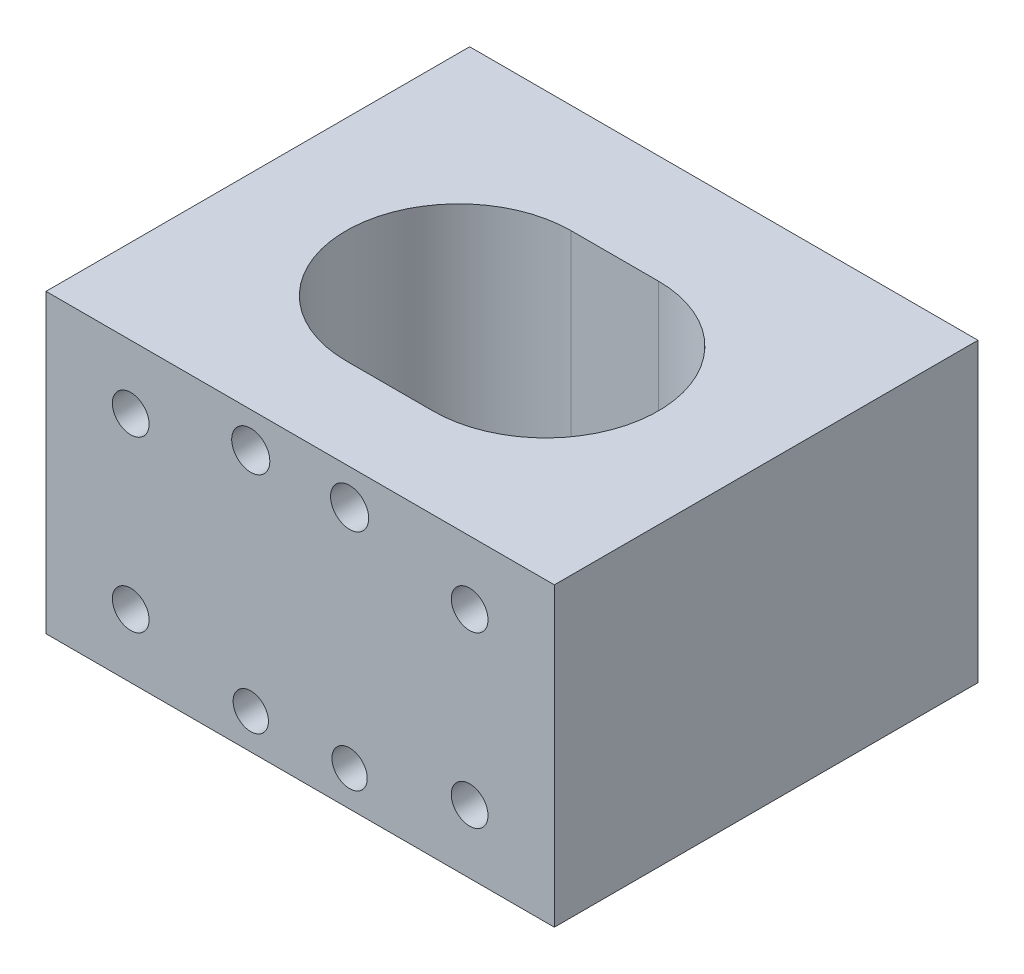
from build123d import *

# Parameters (mm, degrees)
SKETCH_1_W          = 36
SKETCH_1_H          = 21
SKETCH_1_R          = 1.25
SKETCH_1_R_2        = 1.3
SKETCH_1_R_3        = 1.35
EXTRUDE_1_DEPTH     = 30
SKETCH_1_5_R        = 1.3
SKETCH_1_5_R_2      = 1.35
SKETCH_1_5_R_3      = 1.25
CUT_EXTRUDE_1_DEPTH = 4
CUT_EXTRUDE_START   = 30
SKETCH_1_6_R        = 1.35
SKETCH_1_6_R_2      = 1.3
SKETCH_1_6_R_3      = 1.25
CUT_EXTRUDE_2_DEPTH = 4
CUT_EXTRUDE1_DEPTH  = 30


with BuildPart() as part:
    # 스케치1 → 보스-돌출1 (new body)
    with BuildSketch(Plane.XY):
        Rectangle(SKETCH_1_W, SKETCH_1_H)
        with Locations((-3.5, -8)):
            Circle(SKETCH_1_R, mode=Mode.SUBTRACT)
        with Locations((3.5, -8)):
            Circle(SKETCH_1_R, mode=Mode.SUBTRACT)
        with Locations((-12, 6)):
            Circle(SKETCH_1_R_2, mode=Mode.SUBTRACT)
        with Locations((12, 6)):
            Circle(SKETCH_1_R_2, mode=Mode.SUBTRACT)
        with Locations((12, -6)):
            Circle(SKETCH_1_R_2, mode=Mode.SUBTRACT)
        with Locations((-12, -6)):
            Circle(SKETCH_1_R_2, mode=Mode.SUBTRACT)
        with Locations((3.5, 8)):
            Circle(SKETCH_1_R_3, mode=Mode.SUBTRACT)
        with Locations((-3.5, 8)):
            Circle(SKETCH_1_R_3, mode=Mode.SUBTRACT)
        with Locations((12, -6)):
            Circle(SKETCH_1_R_2)
        with Locations((3.5, -8)):
            Circle(SKETCH_1_R)
        with Locations((-3.5, -8)):
            Circle(SKETCH_1_R)
        with Locations((-12, -6)):
            Circle(SKETCH_1_R_2)
        with Locations((-12, 6)):
            Circle(SKETCH_1_R_2)
        with Locations((-3.5, 8)):
            Circle(SKETCH_1_R_3)
        with Locations((3.5, 8)):
            Circle(SKETCH_1_R_3)
        with Locations((12, 6)):
            Circle(SKETCH_1_R_2)
    extrude(amount=EXTRUDE_1_DEPTH)

    # 스케치1<5> → 컷-돌출1 (cut)
    with BuildSketch(Plane.XY):
        with Locations((12, 6)):
            Circle(SKETCH_1_5_R)
        with Locations((3.5, 8)):
            Circle(SKETCH_1_5_R_2)
        with Locations((-3.5, 8)):
            Circle(SKETCH_1_5_R_2)
        with Locations((-12, 6)):
            Circle(SKETCH_1_5_R)
        with Locations((-12, -6)):
            Circle(SKETCH_1_5_R)
        with Locations(Location((-3.5, -8, 0), (0, 0, 180))):
            Circle(SKETCH_1_5_R_3)
        with Locations((3.5, -8)):
            Circle(SKETCH_1_5_R_3)
        with Locations((12, -6)):
            Circle(SKETCH_1_5_R)
    extrude(amount=CUT_EXTRUDE_1_DEPTH, mode=Mode.SUBTRACT)

    # 스케치1<6> → 컷-돌출2 (cut)
    with BuildSketch(Plane.XY.offset(CUT_EXTRUDE_START)):
        with Locations((3.5, 8)):
            Circle(SKETCH_1_6_R)
        with Locations((12, 6)):
            Circle(SKETCH_1_6_R_2)
        with Locations((-3.5, 8)):
            Circle(SKETCH_1_6_R)
        with Locations((-12, 6)):
            Circle(SKETCH_1_6_R_2)
        with Locations((-12, -6)):
            Circle(SKETCH_1_6_R_2)
        with Locations(Location((-3.5, -8, 0), (0, 0, 180))):
            Circle(SKETCH_1_6_R_3)
        with Locations((3.5, -8)):
            Circle(SKETCH_1_6_R_3)
        with Locations((12, -6)):
            Circle(SKETCH_1_6_R_2)
    extrude(amount=-CUT_EXTRUDE_2_DEPTH, mode=Mode.SUBTRACT)

    # Sketch1 → Cut-Extrude1 (cut)
    with BuildSketch(Plane(origin=(0, 10.5, 0), x_dir=(1, 0, 0), z_dir=(0, 1, 0))):
        with BuildLine():
            Line((-3.118018925, -7.687381661), (3.044704105, -7.687381661))
            ThreePointArc((3.044704105, -7.687381661), (11.019992732, -15.662670288), (3.044704105, -23.637958915))
            Line((3.044704105, -23.637958915), (-3.118018925, -23.637958915))
            ThreePointArc((-3.118018925, -23.637958915), (-11.093307551, -15.662670288), (-3.118018925, -7.687381661))
        make_face()
    extrude(amount=-CUT_EXTRUDE1_DEPTH, mode=Mode.SUBTRACT)


solid = part.part
